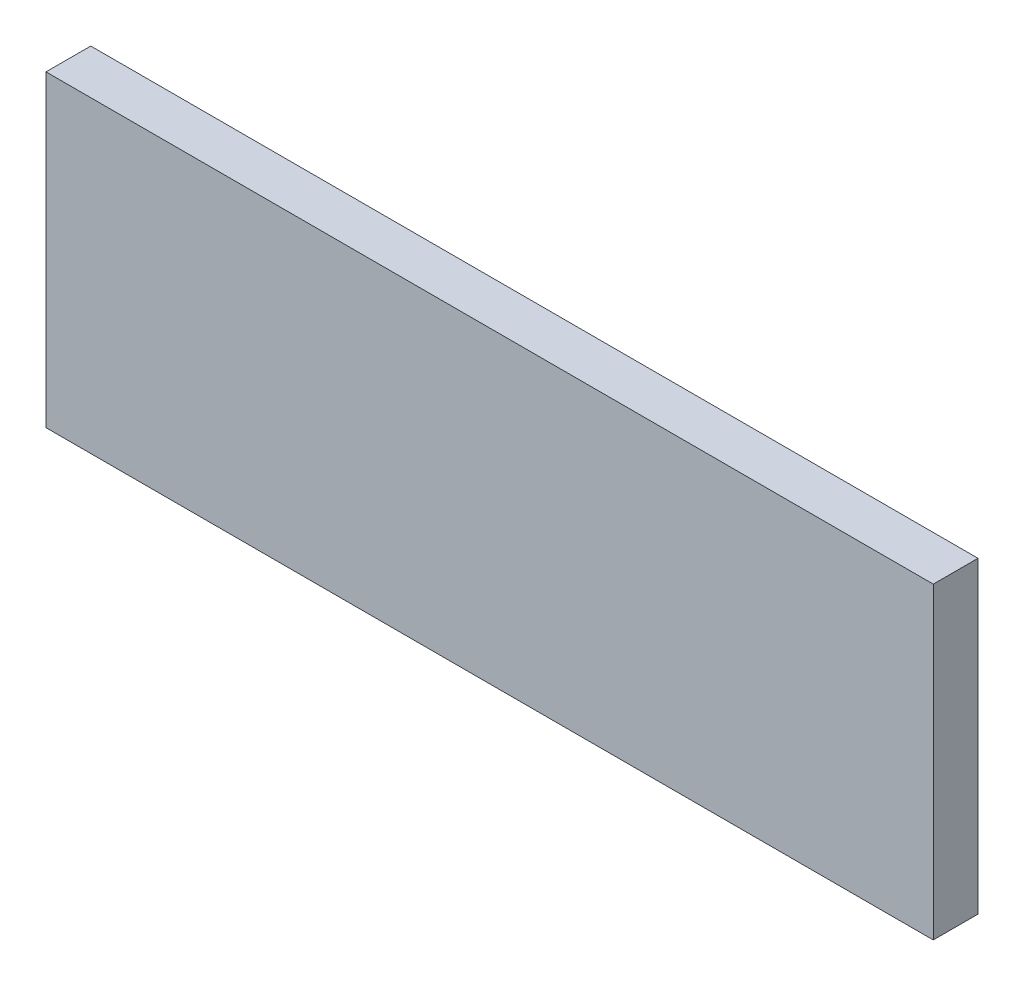
from build123d import *

# Parameters (mm, degrees)
SKETCH_1_W      = 357
SKETCH_1_H      = 124
EXTRUDE_1_DEPTH = 18


with BuildPart() as part:
    # Эскиз1 → Бобышка-Вытянуть1 (new body)
    with BuildSketch(Plane.XY):
        with Locations((160.764989549, -54.399281235)):
            Rectangle(SKETCH_1_W, SKETCH_1_H)
    extrude(amount=EXTRUDE_1_DEPTH)


solid = part.part
